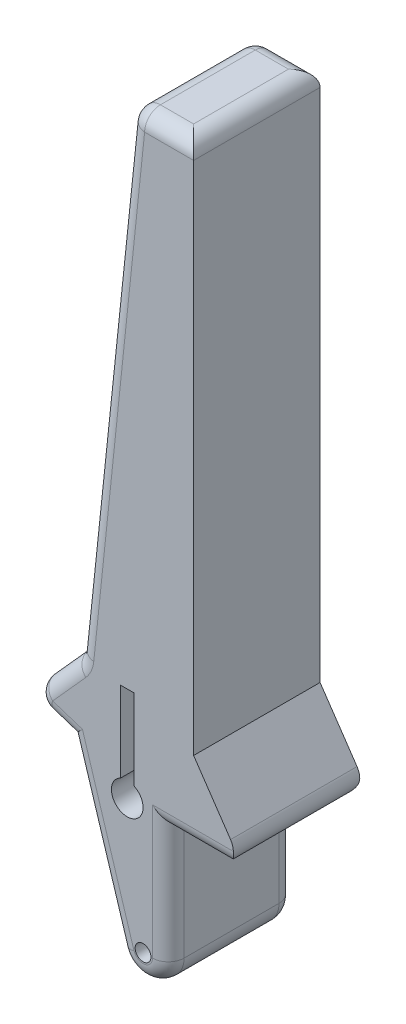
from build123d import *

# Parameters (mm, degrees)
SKETCH1_R           = 2.5
BOSS_EXTRUDE1_DEPTH = 40
FILLET1_R           = 5


with BuildPart() as part:
    # Sketch1 → Boss-Extrude1 (new body)
    with BuildSketch(Plane.XY):
        with BuildLine():
            Line((16, 62), (16, 230))
            Line((16, 230), (-4, 230))
            Line((-4, 230), (-20.724554123, 70.876496741))
            Line((-20.724554123, 70.876496741), (-37.429359571, 52.276779675))
            Line((-37.429359571, 52.276779675), (-23.168143925, 47.627292789))
            Line((-23.168143925, 47.627292789), (-7.640043226, -2.372707211))
            ThreePointArc((-7.640043226, -2.372707211), (1.199927955, -7.909498903), (8, 0))
            Line((8, 0), (8, 37))
            Line((8, 37), (33, 37))
            Line((33, 37), (16, 62))
        make_face()
        Circle(SKETCH1_R, mode=Mode.SUBTRACT)
        with BuildLine():
            Line((-2.875, 69.720325745), (-7.125, 69.720325745))
            Line((-7.125, 69.720325745), (-7.125, 44.246292492))
            ThreePointArc((-7.125, 44.246292492), (-5, 34.720325745), (-2.875, 44.246292492))
            Line((-2.875, 44.246292492), (-2.875, 69.720325745))
        make_face(mode=Mode.SUBTRACT)
    extrude(amount=BOSS_EXTRUDE1_DEPTH)

    # Fillet1
    fillet1_edges = [part.edges().sort_by_distance(p)[0] for p in [
        (20.5, 37, 40),
        (-29.076956847, 61.576638208, 0),
        (-12.362277061, 150.438248371, 0),
        (6, 230, 0),
        (20.5, 37, 0),
        (8, 18.5, 0),
        (1.199927955, -7.909498903, 0),
        (-37.429359571, 52.276779675, 20),
        (-20.724554123, 70.876496741, 20),
        (-4, 230, 20),
        (16, 230, 20),
        (33, 37, 20),
        (6, 230, 40),
        (-12.362277061, 150.438248371, 40),
        (-29.076956847, 61.576638208, 40),
        (-30.298751748, 49.952036232, 40),
        (-15.404093575, 22.627292789, 40),
        (1.199927955, -7.909498903, 40),
        (8, 18.5, 40),
        (-15.404093575, 22.627292789, 0),
        (-30.298751748, 49.952036232, 0),
    ]]
    fillet(fillet1_edges, radius=FILLET1_R)


solid = part.part
